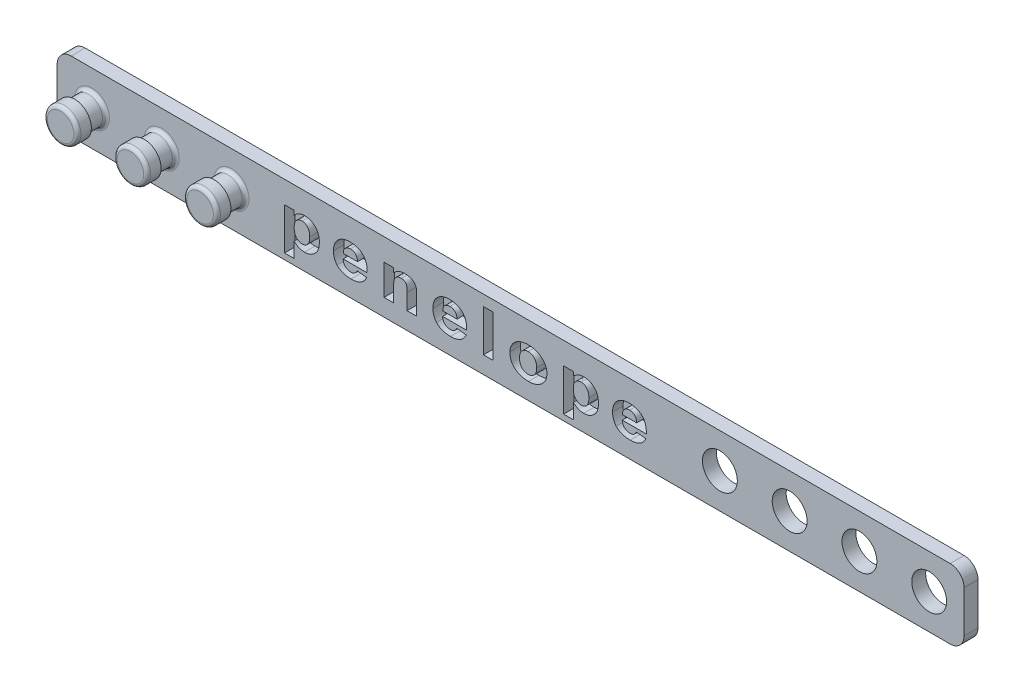
from build123d import *

# Parameters (mm, degrees)
ESTRUSIONE_ESTRUSIONE1_DEPTH  = 2
SCHIZZO3_R                    = 2.5
TAGLIO_ESTRUSIONE3_DEPTH      = 3
TAGLIO_ESTRUSIONE3_DEPTH_BACK = 1
ESTRUSIONE_ESTRUSIONE2_START  = 2
SCHIZZO3_3_R                  = 2
ESTRUSIONE_ESTRUSIONE2_DEPTH  = 2.5
ESTRUSIONE_ESTRUSIONE3_START  = 4.5
SCHIZZO4_R                    = 2.4
ESTRUSIONE_ESTRUSIONE3_DEPTH  = 2
RACCORDO1_R                   = 0.5
RACCORDO2_R                   = 0.5
SCHIZZO5_W                    = 1.384615385
SCHIZZO5_H                    = 6
TAGLIO_ESTRUSIONE4_DEPTH      = 1.5


with BuildPart() as part:
    # Schizzo2 → Estrusione-Estrusione1 (new body)
    with BuildSketch(Plane.XY):
        with BuildLine():
            Line((63, 5), (-63, 5))
            ThreePointArc((-63, 5), (-64.414213562, 4.414213562), (-65, 3))
            Line((-65, 3), (-65, -3))
            ThreePointArc((-65, -3), (-64.414213562, -4.414213562), (-63, -5))
            Line((-63, -5), (63, -5))
            ThreePointArc((63, -5), (64.414213562, -4.414213562), (65, -3))
            Line((65, -3), (65, 3))
            ThreePointArc((65, 3), (64.414213562, 4.414213562), (63, 5))
        make_face()
    extrude(amount=ESTRUSIONE_ESTRUSIONE1_DEPTH)

    # Schizzo3 → Taglio-Estrusione3 (cut, two sides)
    with BuildSketch(Plane.XY) as taglio_estrusione3_sk:
        with Locations((60, 0)):
            Circle(SCHIZZO3_R)
        with Locations((50, 0)):
            Circle(SCHIZZO3_R)
        with Locations((40, 0)):
            Circle(SCHIZZO3_R)
        with Locations((30, 0)):
            Circle(SCHIZZO3_R)
    extrude(amount=TAGLIO_ESTRUSIONE3_DEPTH, mode=Mode.SUBTRACT)
    extrude(taglio_estrusione3_sk.sketch, amount=-TAGLIO_ESTRUSIONE3_DEPTH_BACK, mode=Mode.SUBTRACT)

    # Schizzo3_3 → Estrusione-Estrusione2 (add)
    with BuildSketch(Plane.XY.offset(ESTRUSIONE_ESTRUSIONE2_START)):
        with Locations((-40, 0)):
            Circle(SCHIZZO3_3_R)
        with Locations((-50, 0)):
            Circle(SCHIZZO3_3_R)
        with Locations((-60, 0)):
            Circle(SCHIZZO3_3_R)
    extrude(amount=ESTRUSIONE_ESTRUSIONE2_DEPTH)

    # Schizzo4 → Estrusione-Estrusione3 (add)
    with BuildSketch(Plane.XY.offset(ESTRUSIONE_ESTRUSIONE3_START)):
        with Locations((-60, 0)):
            Circle(SCHIZZO4_R)
        with Locations((-50, 0)):
            Circle(SCHIZZO4_R)
        with Locations((-40, 0)):
            Circle(SCHIZZO4_R)
    extrude(amount=ESTRUSIONE_ESTRUSIONE3_DEPTH)

    # Raccordo1
    raccordo1_edges = [part.edges().sort_by_distance(p)[0] for p in [
        (-52.4, 0, 6.5),
        (-62.4, 0, 6.5),
        (-42.4, 0, 6.5),
    ]]
    fillet(raccordo1_edges, radius=RACCORDO1_R)

    # Raccordo2
    raccordo2_edges = [part.edges().sort_by_distance(p)[0] for p in [
        (-62, 0, 2),
        (-52, 0, 2),
        (-42, 0, 2),
    ]]
    fillet(raccordo2_edges, radius=RACCORDO2_R)

    # Schizzo5 → Taglio-Estrusione4 (cut)
    with BuildSketch(Plane.XY.offset(2)):
        with BuildLine():
            Line((-32.414742948, 1.841375174), (-31.030127563, 1.841375174))
            Line((-31.030127563, 1.841375174), (-31.030127563, 1.209163636))
            add(Edge.make_bspline(
                [(-31.030127563, 1.209163636), (-30.988148819, 1.261603518), (-30.903595393, 1.367227728), (-30.751472112, 1.506108731), (-30.577571326, 1.626230634), (-30.385802673, 1.730842938), (-30.177332356, 1.814634337), (-29.955894402, 1.874590614), (-29.723687417, 1.911722791), (-29.565123269, 1.916081021), (-29.484454486, 1.918298251)],
                knots=[0, 0, 0, 0, 0.913427207, 1.839821568, 2.791542259, 3.784862266, 4.807792984, 5.842477342, 6.902370256, 8, 8, 8, 8], degree=3))
            add(Edge.make_bspline(
                [(-29.484454486, 1.918298251), (-29.413848093, 1.91641964), (-29.27449198, 1.912711817), (-29.069680406, 1.884255315), (-28.872590329, 1.839081013), (-28.683992123, 1.773819531), (-28.504236862, 1.689047217), (-28.33273853, 1.586363816), (-28.169390443, 1.465081575), (-28.015527402, 1.326439344), (-27.872829668, 1.172328129), (-27.750302868, 1.000613533), (-27.646062876, 0.814813455), (-27.560109778, 0.614815139), (-27.496465562, 0.398996898), (-27.447473808, 0.170161699), (-27.420373293, -0.073839297), (-27.416651953, -0.2410942), (-27.414742948, -0.326894057)],
                knots=[0, 0, 0, 0, 0.987307389, 1.948652415, 2.88658439, 3.811688736, 4.734226577, 5.661653329, 6.603127709, 7.575322154, 8.555046118, 9.534818162, 10.518381059, 11.530147679, 12.572536105, 13.660619559, 14.799924537, 16, 16, 16, 16], degree=3))
            add(Edge.make_bspline(
                [(-27.414742948, -0.326894057), (-27.416525308, -0.41510856), (-27.419994828, -0.586825718), (-27.448726748, -0.836776), (-27.498545284, -1.071021162), (-27.565028274, -1.291454797), (-27.653251974, -1.496438936), (-27.76031666, -1.686984713), (-27.889125774, -1.860601878), (-28.034341277, -2.019123006), (-28.193701485, -2.160061374), (-28.362393914, -2.283096825), (-28.539089449, -2.387915288), (-28.724919878, -2.471625643), (-28.918404169, -2.538219661), (-29.119869182, -2.586809984), (-29.330236673, -2.614441318), (-29.473157548, -2.618235882), (-29.545752563, -2.620163287)],
                knots=[0, 0, 0, 0, 1.203052933, 2.341846544, 3.425437307, 4.466049735, 5.477098758, 6.46334188, 7.440489122, 8.419056492, 9.390702261, 10.337298309, 11.263289448, 12.187731242, 13.112318398, 14.050755416, 15.009903613, 16, 16, 16, 16], degree=3))
            add(Edge.make_bspline(
                [(-29.545752563, -2.620163287), (-29.614378587, -2.618884278), (-29.749012791, -2.616375048), (-29.945473045, -2.586714683), (-30.133272417, -2.544899944), (-30.313206973, -2.481102174), (-30.489280603, -2.394248224), (-30.668003765, -2.285616081), (-30.849861303, -2.14944049), (-30.968330876, -2.045681039), (-31.030127563, -1.991557518)],
                knots=[0, 0, 0, 0, 0.99419381, 1.950462614, 2.874845286, 3.780641798, 4.710756482, 5.716995022, 6.8091276, 8, 8, 8, 8], degree=3))
            Line((-31.030127563, -1.991557518), (-31.030127563, -4.158624826))
            Line((-31.030127563, -4.158624826), (-32.414742948, -4.158624826))
            Line((-32.414742948, -4.158624826), (-32.414742948, 1.841375174))
        make_face()
        with BuildLine():
            add(Edge.make_bspline(
                [(-31.030127563, -0.276413287), (-31.029353809, -0.338147334), (-31.027853847, -0.457821938), (-31.012114904, -0.630940481), (-30.986152414, -0.791783602), (-30.948667324, -0.940002441), (-30.902596984, -1.07653333), (-30.844496593, -1.200302484), (-30.776068738, -1.311326378), (-30.697429922, -1.409583795), (-30.610320757, -1.493974857), (-30.520368053, -1.569651003), (-30.424243187, -1.632702513), (-30.32383283, -1.684110346), (-30.218692549, -1.724509499), (-30.109141812, -1.753407666), (-29.99459384, -1.770304996), (-29.916800834, -1.772765748), (-29.877483332, -1.774009441)],
                knots=[0, 0, 0, 0, 1.390678109, 2.695900558, 3.912850633, 5.057934961, 6.137069426, 7.154718523, 8.131716176, 9.069255854, 9.982088381, 10.860527175, 11.714314338, 12.566190392, 13.397734656, 14.247311704, 15.114170698, 16, 16, 16, 16], degree=3))
            add(Edge.make_bspline(
                [(-29.877483332, -1.774009441), (-29.839769405, -1.773186228), (-29.765207861, -1.771558711), (-29.655992864, -1.755654636), (-29.551559449, -1.729245987), (-29.452697378, -1.691479308), (-29.358109798, -1.644581086), (-29.26862678, -1.586438106), (-29.184711079, -1.517261907), (-29.103998802, -1.439187616), (-29.032123103, -1.347465925), (-28.968784632, -1.242729054), (-28.916403551, -1.124193276), (-28.873314059, -0.99247977), (-28.839825697, -0.847253573), (-28.816495565, -0.688893783), (-28.801803911, -0.517074505), (-28.800194413, -0.398239978), (-28.799358332, -0.336509441)],
                knots=[0, 0, 0, 0, 0.888857555, 1.757297558, 2.59593563, 3.42413215, 4.248006676, 5.08130645, 5.934138718, 6.809284526, 7.724072117, 8.673522234, 9.688401476, 10.77287696, 11.937015221, 13.198302606, 14.544612517, 16, 16, 16, 16], degree=3))
            add(Edge.make_bspline(
                [(-28.799358332, -0.336509441), (-28.800242011, -0.278788891), (-28.801950975, -0.167162009), (-28.816173262, -0.005208982), (-28.841252964, 0.145059296), (-28.875995258, 0.284236977), (-28.920199131, 0.411958029), (-28.974005048, 0.528581982), (-29.039615589, 0.632739943), (-29.114385594, 0.725399991), (-29.195831557, 0.806666779), (-29.282345135, 0.877659542), (-29.37353822, 0.937333719), (-29.469176193, 0.988105195), (-29.570783664, 1.024172312), (-29.676188308, 1.053161801), (-29.786919743, 1.068047123), (-29.862223817, 1.070767949), (-29.900319871, 1.072144405)],
                knots=[0, 0, 0, 0, 1.373559056, 2.656352242, 3.864920652, 4.995764563, 6.066269765, 7.077196847, 8.045449753, 8.988058155, 9.904998892, 10.779149403, 11.646565742, 12.49522778, 13.348963198, 14.207000648, 15.092928239, 16, 16, 16, 16], degree=3))
            add(Edge.make_bspline(
                [(-29.900319871, 1.072144405), (-29.940053403, 1.071470806), (-30.018295452, 1.070144376), (-30.132489904, 1.052249846), (-30.24207994, 1.025974677), (-30.346660053, 0.988954798), (-30.445487883, 0.940402719), (-30.539623445, 0.882003585), (-30.627888808, 0.812265453), (-30.711357928, 0.732708544), (-30.787637924, 0.642880813), (-30.852163022, 0.540812437), (-30.907983598, 0.429911312), (-30.952249912, 0.308349693), (-30.987036894, 0.176773469), (-31.011668669, 0.034816858), (-31.027960794, -0.117381517), (-31.029390034, -0.222281746), (-31.030127563, -0.276413287)],
                knots=[0, 0, 0, 0, 0.958889716, 1.888216119, 2.784868528, 3.678696169, 4.561664854, 5.43979386, 6.349718442, 7.273789232, 8.221725463, 9.188155456, 10.183611526, 11.215518146, 12.307101642, 13.467032442, 14.692915734, 16, 16, 16, 16], degree=3))
        make_face(mode=Mode.SUBTRACT)
        with BuildLine():
            Line((-22.014742948, -1.158624826), (-20.630127563, -1.31247098))
            add(Edge.make_bspline(
                [(-20.630127563, -1.31247098), (-20.653039844, -1.364498497), (-20.698214694, -1.467078213), (-20.777860382, -1.613429872), (-20.868192372, -1.749600189), (-20.96881573, -1.875761816), (-21.076319803, -1.994956635), (-21.196765813, -2.101103451), (-21.323862451, -2.201177236), (-21.462828745, -2.288116052), (-21.609833408, -2.366365164), (-21.765163934, -2.435796158), (-21.930589629, -2.491326754), (-22.104339427, -2.538471802), (-22.286963933, -2.575698264), (-22.478465776, -2.601798775), (-22.678728418, -2.617833468), (-22.815192824, -2.619375305), (-22.884935255, -2.620163287)],
                knots=[0, 0, 0, 0, 0.980382276, 1.932964319, 2.870306088, 3.795336826, 4.714929662, 5.634989864, 6.561207498, 7.502617168, 8.458003138, 9.432717288, 10.433735363, 11.464817331, 12.536960572, 13.64632683, 14.797115709, 16, 16, 16, 16], degree=3))
            add(Edge.make_bspline(
                [(-22.884935255, -2.620163287), (-22.994008941, -2.617921182), (-23.205530709, -2.613573166), (-23.511930441, -2.578254171), (-23.796567498, -2.521452836), (-24.059632216, -2.441251767), (-24.300489497, -2.336387696), (-24.519473507, -2.208122882), (-24.718418895, -2.058394751), (-24.83119457, -1.939145851), (-24.887339102, -1.879778672)],
                knots=[0, 0, 0, 0, 1.188722399, 2.305236698, 3.357034434, 4.348894679, 5.297424901, 6.213497234, 7.110602868, 8, 8, 8, 8], degree=3))
            add(Edge.make_bspline(
                [(-24.887339102, -1.879778672), (-24.928620221, -1.829779861), (-25.010994815, -1.730009508), (-25.112694163, -1.564629919), (-25.203981122, -1.392788035), (-25.273173499, -1.208731322), (-25.331235775, -1.016761977), (-25.369724922, -0.814099339), (-25.394557043, -0.601951563), (-25.397737361, -0.457175277), (-25.399358332, -0.383384441)],
                knots=[0, 0, 0, 0, 0.961531517, 1.918692372, 2.876462996, 3.846348486, 4.832604126, 5.851036658, 6.904697689, 8, 8, 8, 8], degree=3))
            add(Edge.make_bspline(
                [(-25.399358332, -0.383384441), (-25.397247065, -0.295956678), (-25.39311703, -0.124931571), (-25.36190876, 0.124322895), (-25.308802574, 0.358896434), (-25.236102495, 0.579013672), (-25.140000181, 0.784037694), (-25.023373547, 0.974582789), (-24.885022406, 1.150058223), (-24.727562665, 1.309824019), (-24.553256043, 1.45165168), (-24.368230042, 1.577907105), (-24.170255568, 1.682565193), (-23.962209762, 1.769897346), (-23.741908395, 1.835340236), (-23.511642206, 1.883583443), (-23.269913627, 1.913067937), (-23.104970755, 1.916530368), (-23.020752563, 1.918298251)],
                knots=[0, 0, 0, 0, 1.124962907, 2.200638483, 3.226304386, 4.215998981, 5.177863753, 6.133781748, 7.084792562, 8.047320423, 9.014477173, 9.972603523, 10.925248221, 11.891401176, 12.871703567, 13.877861348, 14.91645708, 16, 16, 16, 16], degree=3))
            add(Edge.make_bspline(
                [(-23.020752563, 1.918298251), (-22.926516365, 1.916645712), (-22.742746201, 1.913423093), (-22.474969817, 1.882754339), (-22.22258508, 1.832985782), (-21.98575396, 1.761477738), (-21.763363966, 1.671791769), (-21.556535308, 1.560640195), (-21.365450942, 1.428848858), (-21.190370943, 1.27697433), (-21.033107659, 1.104736236), (-20.897394416, 0.910434905), (-20.784223655, 0.694624923), (-20.69250253, 0.457582434), (-20.625196818, 0.198461171), (-20.577010692, -0.081269632), (-20.552080147, -0.382520368), (-20.552822002, -0.590075398), (-20.553204486, -0.697086364)],
                knots=[0, 0, 0, 0, 1.097424668, 2.140089641, 3.135033107, 4.090348584, 5.017710854, 5.923975051, 6.819844303, 7.716394103, 8.618369808, 9.529894562, 10.469380034, 11.450511443, 12.484111964, 13.582875615, 14.753781987, 16, 16, 16, 16], degree=3))
            Line((-20.553204486, -0.697086364), (-24.014742948, -0.697086364))
            add(Edge.make_bspline(
                [(-24.014742948, -0.697086364), (-24.012736237, -0.738434025), (-24.008821648, -0.819092896), (-23.989682872, -0.936267814), (-23.964840965, -1.047224656), (-23.926003315, -1.149955946), (-23.881677623, -1.247084494), (-23.823529585, -1.334927629), (-23.758974075, -1.417548455), (-23.684243546, -1.491615231), (-23.60237683, -1.557923641), (-23.514555303, -1.615029681), (-23.422727627, -1.665612886), (-23.325069129, -1.704314538), (-23.22328256, -1.736658558), (-23.116358838, -1.757313234), (-23.004690044, -1.771226182), (-22.928650062, -1.773067368), (-22.889742948, -1.774009441)],
                knots=[0, 0, 0, 0, 1.136447001, 2.216921819, 3.258218099, 4.254190259, 5.22913527, 6.184874462, 7.140740434, 8.105941997, 9.068692289, 10.030435125, 10.981025473, 11.943838697, 12.911798342, 13.911353256, 14.931309354, 16, 16, 16, 16], degree=3))
            add(Edge.make_bspline(
                [(-22.889742948, -1.774009441), (-22.837957345, -1.77207097), (-22.738078103, -1.768332229), (-22.594375524, -1.742316208), (-22.464004955, -1.695888179), (-22.34524093, -1.632046288), (-22.23961068, -1.546011582), (-22.149073692, -1.437210192), (-22.072760524, -1.306347266), (-22.034649181, -1.20930942), (-22.014742948, -1.158624826)],
                knots=[0, 0, 0, 0, 1.076415669, 2.076090184, 3.021747446, 3.942317475, 4.865821299, 5.835130436, 6.869250088, 8, 8, 8, 8], degree=3))
        make_face()
        with BuildLine():
            add(Edge.make_bspline(
                [(-21.937819871, -0.004778672), (-21.940152467, 0.03771643), (-21.94469932, 0.120550727), (-21.959252822, 0.241549756), (-21.986453936, 0.353762599), (-22.019418004, 0.458981615), (-22.063683153, 0.554891906), (-22.113229443, 0.645436444), (-22.175398175, 0.72545639), (-22.244393358, 0.798178321), (-22.319374698, 0.862593356), (-22.399726962, 0.917871842), (-22.482271749, 0.966679334), (-22.569943061, 1.005269673), (-22.661734543, 1.035364068), (-22.757476134, 1.057069702), (-22.857398611, 1.068892382), (-22.924970501, 1.071045569), (-22.959454486, 1.072144405)],
                knots=[0, 0, 0, 0, 1.225879598, 2.389566535, 3.503617327, 4.54731253, 5.559659915, 6.541557786, 7.513230827, 8.468246763, 9.425769307, 10.354129029, 11.274493263, 12.183721448, 13.106974919, 14.053235803, 15.006507162, 16, 16, 16, 16], degree=3))
            add(Edge.make_bspline(
                [(-22.959454486, 1.072144405), (-22.995945633, 1.071118948), (-23.067965234, 1.069095088), (-23.173530909, 1.05617475), (-23.27399833, 1.032924117), (-23.369929983, 1.00160154), (-23.461343602, 0.961124196), (-23.54693643, 0.909752895), (-23.62822652, 0.8510237), (-23.677444777, 0.805445237), (-23.702242948, 0.782480943)],
                knots=[0, 0, 0, 0, 1.069834141, 2.111444454, 3.111501816, 4.088322384, 5.066201531, 6.03508149, 7.009993721, 8, 8, 8, 8], degree=3))
            add(Edge.make_bspline(
                [(-23.702242948, 0.782480943), (-23.725698907, 0.757764401), (-23.772295109, 0.708664001), (-23.83135252, 0.625480975), (-23.882014292, 0.536628609), (-23.923212889, 0.440713795), (-23.954354417, 0.338280281), (-23.975415555, 0.229489016), (-23.989417512, 0.11457889), (-23.9902677, 0.035730115), (-23.990704486, -0.004778672)],
                knots=[0, 0, 0, 0, 0.947649381, 1.882543458, 2.831635928, 3.79096378, 4.782435372, 5.806196, 6.87292682, 8, 8, 8, 8], degree=3))
            Line((-23.990704486, -0.004778672), (-21.937819871, -0.004778672))
        make_face(mode=Mode.SUBTRACT)
        with BuildLine():
            Line((-13.460896794, -2.54324021), (-14.845512179, -2.54324021))
            Line((-14.845512179, -2.54324021), (-14.845512179, -0.29324021))
            add(Edge.make_bspline(
                [(-14.845512179, -0.29324021), (-14.845761209, -0.236348839), (-14.846236527, -0.127761769), (-14.849274758, 0.026955435), (-14.856778556, 0.165995634), (-14.86595226, 0.289072071), (-14.877858842, 0.396951088), (-14.891916333, 0.488836101), (-14.90769327, 0.565616832), (-14.93515398, 0.645276967), (-14.976733251, 0.729863699), (-15.040532117, 0.81848241), (-15.118183781, 0.894236677), (-15.207882487, 0.958863959), (-15.309403596, 1.008507036), (-15.420481699, 1.047101415), (-15.542237511, 1.068096991), (-15.626688789, 1.070771683), (-15.670031409, 1.072144405)],
                knots=[0, 0, 0, 0, 1.477888563, 2.820807179, 4.019286963, 5.094478482, 6.026566303, 6.837609929, 7.509270846, 8.058896294, 9.022354735, 9.946682558, 10.881323414, 11.828626237, 12.806036439, 13.806555938, 14.874266718, 16, 16, 16, 16], degree=3))
            add(Edge.make_bspline(
                [(-15.670031409, 1.072144405), (-15.726239486, 1.069924834), (-15.836274755, 1.065579711), (-15.997761015, 1.035440951), (-16.149248502, 0.981561356), (-16.291288953, 0.910592372), (-16.416348686, 0.820367956), (-16.525544285, 0.718173191), (-16.608123835, 0.597908015), (-16.662597394, 0.487501299), (-16.693949341, 0.386766847), (-16.713990006, 0.296283662), (-16.730220459, 0.191022266), (-16.74472026, 0.071599072), (-16.754935314, -0.062769285), (-16.763522343, -0.211013174), (-16.768227007, -0.374139332), (-16.768464779, -0.487548408), (-16.768589102, -0.54684598)],
                knots=[0, 0, 0, 0, 1.1926542, 2.334789445, 3.469401267, 4.594803009, 5.691781419, 6.731910779, 7.750839435, 8.769874482, 9.331804178, 9.985584163, 10.734721928, 11.590962064, 12.537715358, 13.593568575, 14.741762601, 16, 16, 16, 16], degree=3))
            Line((-16.768589102, -0.54684598), (-16.768589102, -2.54324021))
            Line((-16.768589102, -2.54324021), (-18.153204486, -2.54324021))
            Line((-18.153204486, -2.54324021), (-18.153204486, 1.841375174))
            Line((-18.153204486, 1.841375174), (-16.768589102, 1.841375174))
            Line((-16.768589102, 1.841375174), (-16.768589102, 1.209163636))
            add(Edge.make_bspline(
                [(-16.768589102, 1.209163636), (-16.713596242, 1.26562433), (-16.605301505, 1.376809602), (-16.425698629, 1.521535078), (-16.236472294, 1.645262593), (-16.03562572, 1.745677937), (-15.824092939, 1.822572207), (-15.602586109, 1.877818464), (-15.37065865, 1.912708119), (-15.212224258, 1.916412472), (-15.131569871, 1.918298251)],
                knots=[0, 0, 0, 0, 1.027741746, 2.023881335, 3.002707471, 3.973007525, 4.947187221, 5.933690324, 6.948101245, 8, 8, 8, 8], degree=3))
            add(Edge.make_bspline(
                [(-15.131569871, 1.918298251), (-15.060569106, 1.916839462), (-14.92086057, 1.913968997), (-14.716520359, 1.886710453), (-14.521350171, 1.843567881), (-14.338007221, 1.783904159), (-14.169893961, 1.711972133), (-14.021678324, 1.628913942), (-13.894995623, 1.536333701), (-13.790045152, 1.432758903), (-13.705026727, 1.320343991), (-13.630952662, 1.203550191), (-13.575113549, 1.077131622), (-13.530337301, 0.940751961), (-13.49792797, 0.786034619), (-13.476060466, 0.605951798), (-13.463569647, 0.396839828), (-13.461824751, 0.247642976), (-13.460896794, 0.168298251)],
                knots=[0, 0, 0, 0, 1.216312869, 2.393344489, 3.526143337, 4.637915733, 5.69280549, 6.655212303, 7.543748753, 8.374022318, 9.171980196, 9.955147646, 10.738796564, 11.533527725, 12.411629124, 13.443015688, 14.640164211, 16, 16, 16, 16], degree=3))
            Line((-13.460896794, 0.168298251), (-13.460896794, -2.54324021))
        make_face()
        with BuildLine():
            Line((-7.753204486, -1.158624826), (-6.368589102, -1.31247098))
            add(Edge.make_bspline(
                [(-6.368589102, -1.31247098), (-6.391501383, -1.364498497), (-6.436676233, -1.467078213), (-6.51632192, -1.613429872), (-6.60665391, -1.749600189), (-6.707277268, -1.875761816), (-6.814781341, -1.994956635), (-6.935227351, -2.101103451), (-7.06232399, -2.201177236), (-7.201290283, -2.288116052), (-7.348294947, -2.366365164), (-7.503625472, -2.435796158), (-7.669051168, -2.491326754), (-7.842800966, -2.538471802), (-8.025425471, -2.575698264), (-8.216927315, -2.601798775), (-8.417189956, -2.617833468), (-8.553654362, -2.619375305), (-8.623396794, -2.620163287)],
                knots=[0, 0, 0, 0, 0.980382276, 1.932964319, 2.870306088, 3.795336826, 4.714929662, 5.634989864, 6.561207498, 7.502617168, 8.458003138, 9.432717288, 10.433735363, 11.464817331, 12.536960572, 13.64632683, 14.797115709, 16, 16, 16, 16], degree=3))
            add(Edge.make_bspline(
                [(-8.623396794, -2.620163287), (-8.73247048, -2.617921182), (-8.943992247, -2.613573166), (-9.250391979, -2.578254171), (-9.535029037, -2.521452836), (-9.798093755, -2.441251767), (-10.038951035, -2.336387696), (-10.257935046, -2.208122882), (-10.456880433, -2.058394751), (-10.569656108, -1.939145851), (-10.62580064, -1.879778672)],
                knots=[0, 0, 0, 0, 1.188722399, 2.305236698, 3.357034434, 4.348894679, 5.297424901, 6.213497234, 7.110602868, 8, 8, 8, 8], degree=3))
            add(Edge.make_bspline(
                [(-10.62580064, -1.879778672), (-10.667081759, -1.829779861), (-10.749456354, -1.730009508), (-10.851155701, -1.564629919), (-10.942442661, -1.392788035), (-11.011635037, -1.208731322), (-11.069697314, -1.016761977), (-11.108186461, -0.814099339), (-11.133018582, -0.601951563), (-11.136198899, -0.457175277), (-11.137819871, -0.383384441)],
                knots=[0, 0, 0, 0, 0.961531517, 1.918692372, 2.876462996, 3.846348486, 4.832604126, 5.851036658, 6.904697689, 8, 8, 8, 8], degree=3))
            add(Edge.make_bspline(
                [(-11.137819871, -0.383384441), (-11.135708604, -0.295956678), (-11.131578569, -0.124931571), (-11.100370299, 0.124322895), (-11.047264112, 0.358896434), (-10.974564033, 0.579013672), (-10.87846172, 0.784037694), (-10.761835086, 0.974582789), (-10.623483944, 1.150058223), (-10.466024203, 1.309824019), (-10.291717582, 1.45165168), (-10.10669158, 1.577907105), (-9.908717106, 1.682565193), (-9.7006713, 1.769897346), (-9.480369933, 1.835340236), (-9.250103744, 1.883583443), (-9.008375165, 1.913067937), (-8.843432294, 1.916530368), (-8.759214102, 1.918298251)],
                knots=[0, 0, 0, 0, 1.124962907, 2.200638483, 3.226304386, 4.215998981, 5.177863753, 6.133781748, 7.084792562, 8.047320423, 9.014477173, 9.972603523, 10.925248221, 11.891401176, 12.871703567, 13.877861348, 14.91645708, 16, 16, 16, 16], degree=3))
            add(Edge.make_bspline(
                [(-8.759214102, 1.918298251), (-8.664977904, 1.916645712), (-8.48120774, 1.913423093), (-8.213431355, 1.882754339), (-7.961046619, 1.832985782), (-7.724215498, 1.761477738), (-7.501825504, 1.671791769), (-7.294996847, 1.560640195), (-7.10391248, 1.428848858), (-6.928832482, 1.27697433), (-6.771569198, 1.104736236), (-6.635855954, 0.910434905), (-6.522685193, 0.694624923), (-6.430964069, 0.457582434), (-6.363658357, 0.198461171), (-6.31547223, -0.081269632), (-6.290541686, -0.382520368), (-6.29128354, -0.590075398), (-6.291666025, -0.697086364)],
                knots=[0, 0, 0, 0, 1.097424668, 2.140089641, 3.135033107, 4.090348584, 5.017710854, 5.923975051, 6.819844303, 7.716394103, 8.618369808, 9.529894562, 10.469380034, 11.450511443, 12.484111964, 13.582875615, 14.753781987, 16, 16, 16, 16], degree=3))
            Line((-6.291666025, -0.697086364), (-9.753204486, -0.697086364))
            add(Edge.make_bspline(
                [(-9.753204486, -0.697086364), (-9.751197775, -0.738434025), (-9.747283187, -0.819092896), (-9.728144411, -0.936267814), (-9.703302504, -1.047224656), (-9.664464853, -1.149955946), (-9.620139162, -1.247084494), (-9.561991123, -1.334927629), (-9.497435614, -1.417548455), (-9.422705085, -1.491615231), (-9.340838368, -1.557923641), (-9.253016841, -1.615029681), (-9.161189165, -1.665612886), (-9.063530668, -1.704314538), (-8.961744098, -1.736658558), (-8.854820376, -1.757313234), (-8.743151582, -1.771226182), (-8.6671116, -1.773067368), (-8.628204486, -1.774009441)],
                knots=[0, 0, 0, 0, 1.136447001, 2.216921819, 3.258218099, 4.254190259, 5.22913527, 6.184874462, 7.140740434, 8.105941997, 9.068692289, 10.030435125, 10.981025473, 11.943838697, 12.911798342, 13.911353256, 14.931309354, 16, 16, 16, 16], degree=3))
            add(Edge.make_bspline(
                [(-8.628204486, -1.774009441), (-8.576418884, -1.77207097), (-8.476539641, -1.768332229), (-8.332837063, -1.742316208), (-8.202466494, -1.695888179), (-8.083702469, -1.632046288), (-7.978072219, -1.546011582), (-7.88753523, -1.437210192), (-7.811222063, -1.306347266), (-7.773110719, -1.20930942), (-7.753204486, -1.158624826)],
                knots=[0, 0, 0, 0, 1.076415669, 2.076090184, 3.021747446, 3.942317475, 4.865821299, 5.835130436, 6.869250088, 8, 8, 8, 8], degree=3))
        make_face()
        with BuildLine():
            add(Edge.make_bspline(
                [(-7.676281409, -0.004778672), (-7.678614006, 0.03771643), (-7.683160858, 0.120550727), (-7.697714361, 0.241549756), (-7.724915475, 0.353762599), (-7.757879543, 0.458981615), (-7.802144691, 0.554891906), (-7.851690982, 0.645436444), (-7.913859713, 0.72545639), (-7.982854897, 0.798178321), (-8.057836236, 0.862593356), (-8.138188501, 0.917871842), (-8.220733287, 0.966679334), (-8.308404599, 1.005269673), (-8.400196082, 1.035364068), (-8.495937673, 1.057069702), (-8.59586015, 1.068892382), (-8.663432039, 1.071045569), (-8.697916025, 1.072144405)],
                knots=[0, 0, 0, 0, 1.225879598, 2.389566535, 3.503617327, 4.54731253, 5.559659915, 6.541557786, 7.513230827, 8.468246763, 9.425769307, 10.354129029, 11.274493263, 12.183721448, 13.106974919, 14.053235803, 15.006507162, 16, 16, 16, 16], degree=3))
            add(Edge.make_bspline(
                [(-8.697916025, 1.072144405), (-8.734407171, 1.071118948), (-8.806426772, 1.069095088), (-8.911992448, 1.05617475), (-9.012459868, 1.032924117), (-9.108391521, 1.00160154), (-9.19980514, 0.961124196), (-9.285397969, 0.909752895), (-9.366688059, 0.8510237), (-9.415906316, 0.805445237), (-9.440704486, 0.782480943)],
                knots=[0, 0, 0, 0, 1.069834141, 2.111444454, 3.111501816, 4.088322384, 5.066201531, 6.03508149, 7.009993721, 8, 8, 8, 8], degree=3))
            add(Edge.make_bspline(
                [(-9.440704486, 0.782480943), (-9.464160445, 0.757764401), (-9.510756648, 0.708664001), (-9.569814059, 0.625480975), (-9.62047583, 0.536628609), (-9.661674428, 0.440713795), (-9.692815955, 0.338280281), (-9.713877094, 0.229489016), (-9.727879051, 0.11457889), (-9.728729238, 0.035730115), (-9.729166025, -0.004778672)],
                knots=[0, 0, 0, 0, 0.947649381, 1.882543458, 2.831635928, 3.79096378, 4.782435372, 5.806196, 6.87292682, 8, 8, 8, 8], degree=3))
            Line((-9.729166025, -0.004778672), (-7.676281409, -0.004778672))
        make_face(mode=Mode.SUBTRACT)
        with Locations((-3.199358333, 0.45675979)):
            Rectangle(SCHIZZO5_W, SCHIZZO5_H)
        with BuildLine():
            add(Edge.make_bspline(
                [(-0.10705064, -0.289634441), (-0.106234223, -0.241913545), (-0.104610625, -0.147011696), (-0.088153869, -0.005191149), (-0.061911368, 0.135449046), (-0.024479188, 0.274737714), (0.023149451, 0.41258408), (0.078960307, 0.550225943), (0.148468669, 0.685537759), (0.225616591, 0.819852682), (0.313272048, 0.94911162), (0.409202745, 1.072372568), (0.515361577, 1.186534454), (0.63020483, 1.292576012), (0.752775896, 1.391416985), (0.884221483, 1.481711345), (1.024569467, 1.563720198), (1.172871923, 1.637663148), (1.327926988, 1.703512587), (1.487812283, 1.761624288), (1.653003013, 1.809398955), (1.822339076, 1.848874341), (1.995930207, 1.880669559), (2.174192442, 1.901673573), (2.356678761, 1.915352229), (2.479863664, 1.917310608), (2.541987821, 1.918298251)],
                knots=[0, 0, 0, 0, 0.892153315, 1.774212247, 2.666239693, 3.565912871, 4.468700838, 5.392633959, 6.340946444, 7.311234993, 8.287982592, 9.259283199, 10.229571748, 11.199860297, 12.180480081, 13.171861525, 14.179364962, 15.218146005, 16.268910382, 17.328374632, 18.397754928, 19.482796902, 20.579214358, 21.696328417, 22.838220824, 24, 24, 24, 24], degree=3))
            add(Edge.make_bspline(
                [(2.541987821, 1.918298251), (2.637018912, 1.916596923), (2.823569559, 1.913257135), (3.096563436, 1.882779499), (3.356199021, 1.832310696), (3.602914188, 1.762599423), (3.836748798, 1.672914118), (4.056605136, 1.560908024), (4.264571597, 1.431685208), (4.455442315, 1.28080466), (4.63115537, 1.118109262), (4.783115244, 0.940717852), (4.911167236, 0.752834266), (5.018747156, 0.555908995), (5.100383773, 0.346960666), (5.157953423, 0.12752348), (5.193817483, -0.102160025), (5.198339788, -0.259053564), (5.200641668, -0.338913287)],
                knots=[0, 0, 0, 0, 1.168819114, 2.294448674, 3.374196973, 4.419546203, 5.444725802, 6.449886956, 7.450930861, 8.451695636, 9.438526269, 10.392816407, 11.318364501, 12.231386041, 13.147595051, 14.070567207, 15.017907485, 16, 16, 16, 16], degree=3))
            add(Edge.make_bspline(
                [(5.200641668, -0.338913287), (5.198338275, -0.419570979), (5.193823735, -0.577656195), (5.158088641, -0.809470991), (5.099207963, -1.030864105), (5.01603462, -1.241762392), (4.909124692, -1.442150544), (4.778486709, -1.631282673), (4.6247439, -1.810276201), (4.448706883, -1.976130622), (4.254891437, -2.126022402), (4.048905105, -2.260144881), (3.828505875, -2.370169028), (3.597091037, -2.462155513), (3.352798725, -2.533357479), (3.096432024, -2.582634625), (2.828103081, -2.615671813), (2.645055203, -2.618645249), (2.551603206, -2.620163287)],
                knots=[0, 0, 0, 0, 0.990742207, 1.941807309, 2.874448347, 3.800517735, 4.721114402, 5.6592354, 6.619316861, 7.615292381, 8.625642678, 9.626606269, 10.630555634, 11.647123529, 12.683114849, 13.751899808, 14.85227048, 16, 16, 16, 16], degree=3))
            add(Edge.make_bspline(
                [(2.551603206, -2.620163287), (2.434829598, -2.617013589), (2.203381454, -2.610770809), (1.860326354, -2.55805631), (1.525781695, -2.474081703), (1.255019204, -2.377068173), (1.04857538, -2.280874184), (0.901935847, -2.202248161), (0.765137375, -2.114834694), (0.637345777, -2.020595196), (0.520765959, -1.916004547), (0.412022939, -1.806130344), (0.314291029, -1.686926657), (0.225088143, -1.561272237), (0.146802252, -1.426707438), (0.078122691, -1.285555351), (0.021844469, -1.136382397), (-0.025057211, -0.980966608), (-0.062550818, -0.818421608), (-0.088645602, -0.648501026), (-0.104683975, -0.471437567), (-0.106252225, -0.350967295), (-0.10705064, -0.289634441)],
                knots=[0, 0, 0, 0, 1.754821062, 3.478098208, 5.204856163, 6.934972592, 7.791919291, 8.62740757, 9.434468537, 10.230758554, 11.011589624, 11.786801538, 12.552619736, 13.326356014, 14.101146605, 14.890480792, 15.683597916, 16.495342993, 17.329657986, 18.189225582, 19.078113134, 20, 20, 20, 20], degree=3))
        make_face()
        with BuildLine():
            add(Edge.make_bspline(
                [(1.277564745, -0.350932518), (1.278742377, -0.406665659), (1.281035465, -0.515189236), (1.298117394, -0.673120658), (1.325407201, -0.821097741), (1.363261636, -0.959158167), (1.414698625, -1.086410825), (1.475439525, -1.20449176), (1.547917304, -1.312328992), (1.631281534, -1.408495367), (1.722732945, -1.493851862), (1.820239403, -1.567939024), (1.921861065, -1.633354282), (2.030044339, -1.684336401), (2.143215758, -1.724512848), (2.261141589, -1.753408977), (2.384444828, -1.770357381), (2.468217893, -1.772779877), (2.510737821, -1.774009441)],
                knots=[0, 0, 0, 0, 1.261122631, 2.455658127, 3.590224407, 4.663807676, 5.689176293, 6.690860023, 7.66407059, 8.62195539, 9.564962881, 10.489837305, 11.390392368, 12.294773396, 13.189512901, 14.104332829, 15.037833555, 16, 16, 16, 16], degree=3))
            add(Edge.make_bspline(
                [(2.510737821, -1.774009441), (2.553257091, -1.772778569), (2.637028859, -1.770353496), (2.760341544, -1.753423856), (2.878232648, -1.724458748), (2.991189849, -1.684654713), (3.098593675, -1.632939601), (3.199967002, -1.568380612), (3.296345043, -1.493363793), (3.388286316, -1.40853598), (3.470659388, -1.311123651), (3.543910525, -1.203665745), (3.603143944, -1.084553605), (3.654695371, -0.956770605), (3.692339783, -0.817458298), (3.72014927, -0.668390113), (3.73523951, -0.508691762), (3.737789072, -0.3990383), (3.739103206, -0.342519057)],
                knots=[0, 0, 0, 0, 0.959787324, 1.890979811, 2.803537691, 3.6960648, 4.590057171, 5.488385458, 6.403807395, 7.344483139, 8.306866501, 9.277670639, 10.272734579, 11.303970914, 12.383610311, 13.524262839, 14.723918153, 16, 16, 16, 16], degree=3))
            add(Edge.make_bspline(
                [(3.739103206, -0.342519057), (3.737784291, -0.287202734), (3.735227046, -0.179949848), (3.720225845, -0.023817666), (3.691975611, 0.122337438), (3.65497929, 0.259439124), (3.602896996, 0.385438202), (3.543551693, 0.503188802), (3.471084782, 0.610418817), (3.38785148, 0.706699217), (3.296399519, 0.791544855), (3.199952871, 0.866503617), (3.09859741, 0.931077726), (2.991188853, 0.982788834), (2.878232921, 1.022593943), (2.760341469, 1.051558756), (2.637028878, 1.068488476), (2.553257098, 1.070913538), (2.510737821, 1.072144405)],
                knots=[0, 0, 0, 0, 1.258499145, 2.440105511, 3.562593637, 4.641696817, 5.663881304, 6.658431284, 7.636645689, 8.599455527, 9.547311563, 10.469721028, 11.374906364, 12.275722688, 13.175062564, 14.09458611, 15.032886502, 16, 16, 16, 16], degree=3))
            add(Edge.make_bspline(
                [(2.510737821, 1.072144405), (2.468217893, 1.070914841), (2.384444828, 1.068492345), (2.261141589, 1.05154394), (2.143215758, 1.022647812), (2.030044339, 0.982471365), (1.921861065, 0.931489246), (1.820239403, 0.866073987), (1.722732945, 0.791986826), (1.631281534, 0.706630331), (1.547917304, 0.610463956), (1.475439525, 0.502626723), (1.414698625, 0.384545789), (1.363261636, 0.25729313), (1.325407201, 0.119232704), (1.298117394, -0.028744378), (1.281035465, -0.186675801), (1.278742377, -0.295199378), (1.277564745, -0.350932518)],
                knots=[0, 0, 0, 0, 0.962166445, 1.895667171, 2.810487099, 3.705226604, 4.609607632, 5.510162695, 6.435037119, 7.37804461, 8.33592941, 9.309139977, 10.310823707, 11.336192324, 12.409775593, 13.544341873, 14.738877369, 16, 16, 16, 16], degree=3))
        make_face(mode=Mode.SUBTRACT)
        with BuildLine():
            Line((7.600641668, 1.841375174), (8.985257052, 1.841375174))
            Line((8.985257052, 1.841375174), (8.985257052, 1.209163636))
            add(Edge.make_bspline(
                [(8.985257052, 1.209163636), (9.027235797, 1.261603518), (9.111789222, 1.367227728), (9.263912504, 1.506108731), (9.437813289, 1.626230634), (9.629581942, 1.730842938), (9.83805226, 1.814634337), (10.059490214, 1.874590614), (10.291697198, 1.911722791), (10.450261347, 1.916081021), (10.530930129, 1.918298251)],
                knots=[0, 0, 0, 0, 0.913427207, 1.839821568, 2.791542259, 3.784862266, 4.807792984, 5.842477342, 6.902370256, 8, 8, 8, 8], degree=3))
            add(Edge.make_bspline(
                [(10.530930129, 1.918298251), (10.601536523, 1.91641964), (10.740892635, 1.912711817), (10.945704209, 1.884255315), (11.142794286, 1.839081013), (11.331392492, 1.773819531), (11.511147754, 1.689047217), (11.682646085, 1.586363816), (11.845994172, 1.465081575), (11.999857214, 1.326439344), (12.142554947, 1.172328129), (12.265081747, 1.000613533), (12.369321739, 0.814813455), (12.455274837, 0.614815139), (12.518919054, 0.398996898), (12.567910807, 0.170161699), (12.595011323, -0.073839297), (12.598732663, -0.2410942), (12.600641668, -0.326894057)],
                knots=[0, 0, 0, 0, 0.987307389, 1.948652415, 2.88658439, 3.811688736, 4.734226577, 5.661653329, 6.603127709, 7.575322154, 8.555046118, 9.534818162, 10.518381059, 11.530147679, 12.572536105, 13.660619559, 14.799924537, 16, 16, 16, 16], degree=3))
            add(Edge.make_bspline(
                [(12.600641668, -0.326894057), (12.598859307, -0.41510856), (12.595389788, -0.586825718), (12.566657867, -0.836776), (12.516839331, -1.071021162), (12.450356342, -1.291454797), (12.362132642, -1.496438936), (12.255067955, -1.686984713), (12.126258842, -1.860601878), (11.981043339, -2.019123006), (11.821683131, -2.160061374), (11.652990701, -2.283096825), (11.476295167, -2.387915288), (11.290464737, -2.471625643), (11.096980446, -2.538219661), (10.895515433, -2.586809984), (10.685147942, -2.614441318), (10.542227068, -2.618235882), (10.469632052, -2.620163287)],
                knots=[0, 0, 0, 0, 1.203052933, 2.341846544, 3.425437307, 4.466049735, 5.477098758, 6.46334188, 7.440489122, 8.419056492, 9.390702261, 10.337298309, 11.263289448, 12.187731242, 13.112318398, 14.050755416, 15.009903613, 16, 16, 16, 16], degree=3))
            add(Edge.make_bspline(
                [(10.469632052, -2.620163287), (10.401006029, -2.618884278), (10.266371824, -2.616375048), (10.069911571, -2.586714683), (9.882112198, -2.544899944), (9.702177643, -2.481102174), (9.526104013, -2.394248224), (9.34738085, -2.285616081), (9.165523313, -2.14944049), (9.04705374, -2.045681039), (8.985257052, -1.991557518)],
                knots=[0, 0, 0, 0, 0.99419381, 1.950462614, 2.874845286, 3.780641798, 4.710756482, 5.716995022, 6.8091276, 8, 8, 8, 8], degree=3))
            Line((8.985257052, -1.991557518), (8.985257052, -4.158624826))
            Line((8.985257052, -4.158624826), (7.600641668, -4.158624826))
            Line((7.600641668, -4.158624826), (7.600641668, 1.841375174))
        make_face()
        with BuildLine():
            add(Edge.make_bspline(
                [(8.985257052, -0.276413287), (8.986030806, -0.338147334), (8.987530768, -0.457821938), (9.003269712, -0.630940481), (9.029232202, -0.791783602), (9.066717292, -0.940002441), (9.112787632, -1.07653333), (9.170888022, -1.200302484), (9.239315877, -1.311326378), (9.317954693, -1.409583795), (9.405063858, -1.493974857), (9.495016562, -1.569651003), (9.591141428, -1.632702513), (9.691551785, -1.684110346), (9.796692067, -1.724509499), (9.906242803, -1.753407666), (10.020790776, -1.770304996), (10.098583782, -1.772765748), (10.137901283, -1.774009441)],
                knots=[0, 0, 0, 0, 1.390678109, 2.695900558, 3.912850633, 5.057934961, 6.137069426, 7.154718523, 8.131716176, 9.069255854, 9.982088381, 10.860527175, 11.714314338, 12.566190392, 13.397734656, 14.247311704, 15.114170698, 16, 16, 16, 16], degree=3))
            add(Edge.make_bspline(
                [(10.137901283, -1.774009441), (10.17561521, -1.773186228), (10.250176754, -1.771558711), (10.359391752, -1.755654636), (10.463825166, -1.729245987), (10.562687237, -1.691479308), (10.657274817, -1.644581086), (10.746757836, -1.586438106), (10.830673537, -1.517261907), (10.911385813, -1.439187616), (10.983261512, -1.347465925), (11.046599983, -1.242729054), (11.098981065, -1.124193276), (11.142070556, -0.99247977), (11.175558918, -0.847253573), (11.19888905, -0.688893783), (11.213580705, -0.517074505), (11.215190203, -0.398239978), (11.216026283, -0.336509441)],
                knots=[0, 0, 0, 0, 0.888857555, 1.757297558, 2.59593563, 3.42413215, 4.248006676, 5.08130645, 5.934138718, 6.809284526, 7.724072117, 8.673522234, 9.688401476, 10.77287696, 11.937015221, 13.198302606, 14.544612517, 16, 16, 16, 16], degree=3))
            add(Edge.make_bspline(
                [(11.216026283, -0.336509441), (11.215142604, -0.278788891), (11.21343364, -0.167162009), (11.199211354, -0.005208982), (11.174131651, 0.145059296), (11.139389358, 0.284236977), (11.095185484, 0.411958029), (11.041379568, 0.528581982), (10.975769027, 0.632739943), (10.900999021, 0.725399991), (10.819553058, 0.806666779), (10.73303948, 0.877659542), (10.641846396, 0.937333719), (10.546208423, 0.988105195), (10.444600951, 1.024172312), (10.339196308, 1.053161801), (10.228464872, 1.068047123), (10.153160798, 1.070767949), (10.115064745, 1.072144405)],
                knots=[0, 0, 0, 0, 1.373559056, 2.656352242, 3.864920652, 4.995764563, 6.066269765, 7.077196847, 8.045449753, 8.988058155, 9.904998892, 10.779149403, 11.646565742, 12.49522778, 13.348963198, 14.207000648, 15.092928239, 16, 16, 16, 16], degree=3))
            add(Edge.make_bspline(
                [(10.115064745, 1.072144405), (10.075331212, 1.071470806), (9.997089163, 1.070144376), (9.882894711, 1.052249846), (9.773304676, 1.025974677), (9.668724563, 0.988954798), (9.569896732, 0.940402719), (9.47576117, 0.882003585), (9.387495807, 0.812265453), (9.304026688, 0.732708544), (9.227746691, 0.642880813), (9.163221593, 0.540812437), (9.107401017, 0.429911312), (9.063134704, 0.308349693), (9.028347721, 0.176773469), (9.003715946, 0.034816858), (8.987423821, -0.117381517), (8.985994581, -0.222281746), (8.985257052, -0.276413287)],
                knots=[0, 0, 0, 0, 0.958889716, 1.888216119, 2.784868528, 3.678696169, 4.561664854, 5.43979386, 6.349718442, 7.273789232, 8.221725463, 9.188155456, 10.183611526, 11.215518146, 12.307101642, 13.467032442, 14.692915734, 16, 16, 16, 16], degree=3))
        make_face(mode=Mode.SUBTRACT)
        with BuildLine():
            Line((18.000641668, -1.158624826), (19.385257052, -1.31247098))
            add(Edge.make_bspline(
                [(19.385257052, -1.31247098), (19.362344771, -1.364498497), (19.317169921, -1.467078213), (19.237524233, -1.613429872), (19.147192244, -1.749600189), (19.046568885, -1.875761816), (18.939064813, -1.994956635), (18.818618803, -2.101103451), (18.691522164, -2.201177236), (18.552555871, -2.288116052), (18.405551207, -2.366365164), (18.250220682, -2.435796158), (18.084794986, -2.491326754), (17.911045188, -2.538471802), (17.728420683, -2.575698264), (17.536918839, -2.601798775), (17.336656197, -2.617833468), (17.200191792, -2.619375305), (17.13044936, -2.620163287)],
                knots=[0, 0, 0, 0, 0.980382276, 1.932964319, 2.870306088, 3.795336826, 4.714929662, 5.634989864, 6.561207498, 7.502617168, 8.458003138, 9.432717288, 10.433735363, 11.464817331, 12.536960572, 13.64632683, 14.797115709, 16, 16, 16, 16], degree=3))
            add(Edge.make_bspline(
                [(17.13044936, -2.620163287), (17.021375674, -2.617921182), (16.809853907, -2.613573166), (16.503454175, -2.578254171), (16.218817117, -2.521452836), (15.955752399, -2.441251767), (15.714895119, -2.336387696), (15.495911108, -2.208122882), (15.296965721, -2.058394751), (15.184190046, -1.939145851), (15.128045514, -1.879778672)],
                knots=[0, 0, 0, 0, 1.188722399, 2.305236698, 3.357034434, 4.348894679, 5.297424901, 6.213497234, 7.110602868, 8, 8, 8, 8], degree=3))
            add(Edge.make_bspline(
                [(15.128045514, -1.879778672), (15.086764394, -1.829779861), (15.0043898, -1.730009508), (14.902690453, -1.564629919), (14.811403493, -1.392788035), (14.742211116, -1.208731322), (14.68414884, -1.016761977), (14.645659693, -0.814099339), (14.620827572, -0.601951563), (14.617647255, -0.457175277), (14.616026283, -0.383384441)],
                knots=[0, 0, 0, 0, 0.961531517, 1.918692372, 2.876462996, 3.846348486, 4.832604126, 5.851036658, 6.904697689, 8, 8, 8, 8], degree=3))
            add(Edge.make_bspline(
                [(14.616026283, -0.383384441), (14.61813755, -0.295956678), (14.622267585, -0.124931571), (14.653475855, 0.124322895), (14.706582042, 0.358896434), (14.779282121, 0.579013672), (14.875384434, 0.784037694), (14.992011068, 0.974582789), (15.130362209, 1.150058223), (15.28782195, 1.309824019), (15.462128572, 1.45165168), (15.647154573, 1.577907105), (15.845129048, 1.682565193), (16.053174853, 1.769897346), (16.273476221, 1.835340236), (16.50374241, 1.883583443), (16.745470989, 1.913067937), (16.91041386, 1.916530368), (16.994632052, 1.918298251)],
                knots=[0, 0, 0, 0, 1.124962907, 2.200638483, 3.226304386, 4.215998981, 5.177863753, 6.133781748, 7.084792562, 8.047320423, 9.014477173, 9.972603523, 10.925248221, 11.891401176, 12.871703567, 13.877861348, 14.91645708, 16, 16, 16, 16], degree=3))
            add(Edge.make_bspline(
                [(16.994632052, 1.918298251), (17.08886825, 1.916645712), (17.272638414, 1.913423093), (17.540414799, 1.882754339), (17.792799535, 1.832985782), (18.029630656, 1.761477738), (18.25202065, 1.671791769), (18.458849307, 1.560640195), (18.649933674, 1.428848858), (18.825013672, 1.27697433), (18.982276956, 1.104736236), (19.1179902, 0.910434905), (19.231160961, 0.694624923), (19.322882085, 0.457582434), (19.390187797, 0.198461171), (19.438373924, -0.081269632), (19.463304468, -0.382520368), (19.462562614, -0.590075398), (19.462180129, -0.697086364)],
                knots=[0, 0, 0, 0, 1.097424668, 2.140089641, 3.135033107, 4.090348584, 5.017710854, 5.923975051, 6.819844303, 7.716394103, 8.618369808, 9.529894562, 10.469380034, 11.450511443, 12.484111964, 13.582875615, 14.753781987, 16, 16, 16, 16], degree=3))
            Line((19.462180129, -0.697086364), (16.000641668, -0.697086364))
            add(Edge.make_bspline(
                [(16.000641668, -0.697086364), (16.002648379, -0.738434025), (16.006562967, -0.819092896), (16.025701743, -0.936267814), (16.05054365, -1.047224656), (16.089381301, -1.149955946), (16.133706992, -1.247084494), (16.191855031, -1.334927629), (16.25641054, -1.417548455), (16.331141069, -1.491615231), (16.413007786, -1.557923641), (16.500829313, -1.615029681), (16.592656989, -1.665612886), (16.690315486, -1.704314538), (16.792102055, -1.736658558), (16.899025778, -1.757313234), (17.010694572, -1.771226182), (17.086734554, -1.773067368), (17.125641668, -1.774009441)],
                knots=[0, 0, 0, 0, 1.136447001, 2.216921819, 3.258218099, 4.254190259, 5.22913527, 6.184874462, 7.140740434, 8.105941997, 9.068692289, 10.030435125, 10.981025473, 11.943838697, 12.911798342, 13.911353256, 14.931309354, 16, 16, 16, 16], degree=3))
            add(Edge.make_bspline(
                [(17.125641668, -1.774009441), (17.17742727, -1.77207097), (17.277306513, -1.768332229), (17.421009091, -1.742316208), (17.55137966, -1.695888179), (17.670143685, -1.632046288), (17.775773935, -1.546011582), (17.866310923, -1.437210192), (17.942624091, -1.306347266), (17.980735434, -1.20930942), (18.000641668, -1.158624826)],
                knots=[0, 0, 0, 0, 1.076415669, 2.076090184, 3.021747446, 3.942317475, 4.865821299, 5.835130436, 6.869250088, 8, 8, 8, 8], degree=3))
        make_face()
        with BuildLine():
            add(Edge.make_bspline(
                [(18.077564745, -0.004778672), (18.075232148, 0.03771643), (18.070685296, 0.120550727), (18.056131793, 0.241549756), (18.028930679, 0.353762599), (17.995966611, 0.458981615), (17.951701463, 0.554891906), (17.902155172, 0.645436444), (17.839986441, 0.72545639), (17.770991257, 0.798178321), (17.696009917, 0.862593356), (17.615657653, 0.917871842), (17.533112866, 0.966679334), (17.445441555, 1.005269673), (17.353650072, 1.035364068), (17.257908481, 1.057069702), (17.157986004, 1.068892382), (17.090414115, 1.071045569), (17.055930129, 1.072144405)],
                knots=[0, 0, 0, 0, 1.225879598, 2.389566535, 3.503617327, 4.54731253, 5.559659915, 6.541557786, 7.513230827, 8.468246763, 9.425769307, 10.354129029, 11.274493263, 12.183721448, 13.106974919, 14.053235803, 15.006507162, 16, 16, 16, 16], degree=3))
            add(Edge.make_bspline(
                [(17.055930129, 1.072144405), (17.019438983, 1.071118948), (16.947419381, 1.069095088), (16.841853706, 1.05617475), (16.741386286, 1.032924117), (16.645454633, 1.00160154), (16.554041014, 0.961124196), (16.468448185, 0.909752895), (16.387158095, 0.8510237), (16.337939838, 0.805445237), (16.313141668, 0.782480943)],
                knots=[0, 0, 0, 0, 1.069834141, 2.111444454, 3.111501816, 4.088322384, 5.066201531, 6.03508149, 7.009993721, 8, 8, 8, 8], degree=3))
            add(Edge.make_bspline(
                [(16.313141668, 0.782480943), (16.289685708, 0.757764401), (16.243089506, 0.708664001), (16.184032095, 0.625480975), (16.133370324, 0.536628609), (16.092171726, 0.440713795), (16.061030199, 0.338280281), (16.03996906, 0.229489016), (16.025967103, 0.11457889), (16.025116915, 0.035730115), (16.024680129, -0.004778672)],
                knots=[0, 0, 0, 0, 0.947649381, 1.882543458, 2.831635928, 3.79096378, 4.782435372, 5.806196, 6.87292682, 8, 8, 8, 8], degree=3))
            Line((16.024680129, -0.004778672), (18.077564745, -0.004778672))
        make_face(mode=Mode.SUBTRACT)
    extrude(amount=-TAGLIO_ESTRUSIONE4_DEPTH, mode=Mode.SUBTRACT)


solid = part.part
